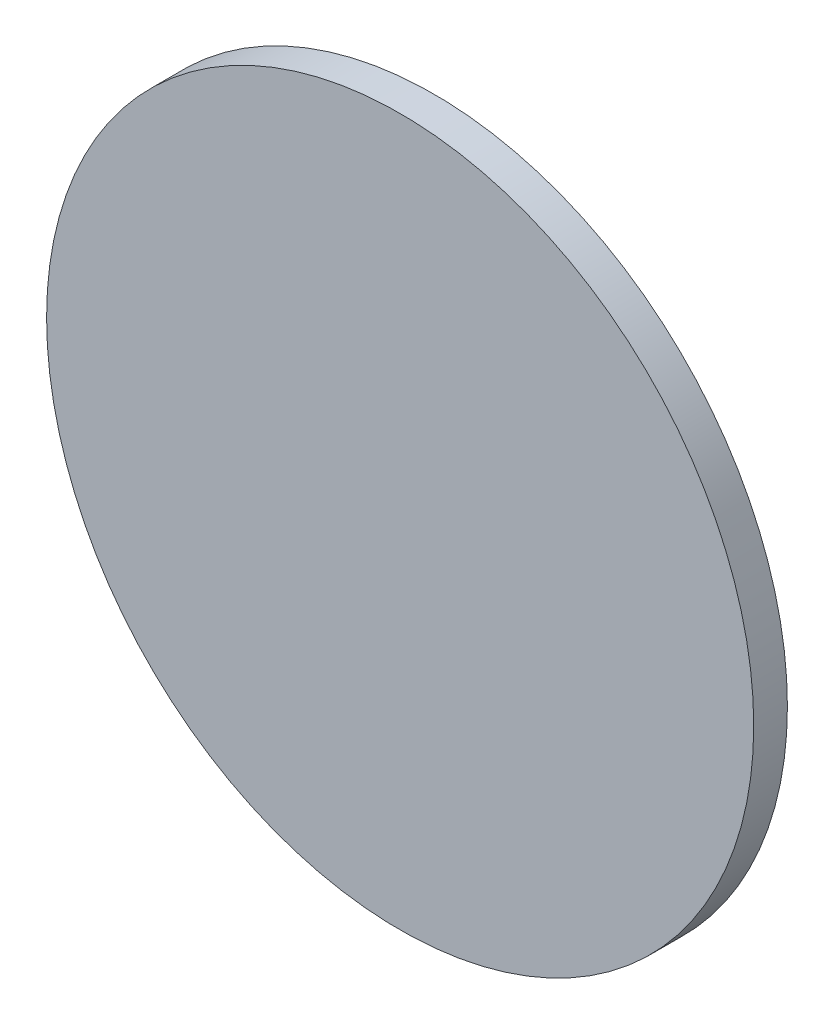
from build123d import *

# Parameters (mm, degrees)
ESQUISSE1_R        = 42
BOSS_EXTRU_1_DEPTH = 4


with BuildPart() as part:
    # Esquisse1 → Boss.-Extru.1 (new body)
    with BuildSketch(Plane.XY):
        Circle(ESQUISSE1_R)
    extrude(amount=BOSS_EXTRU_1_DEPTH)


solid = part.part
